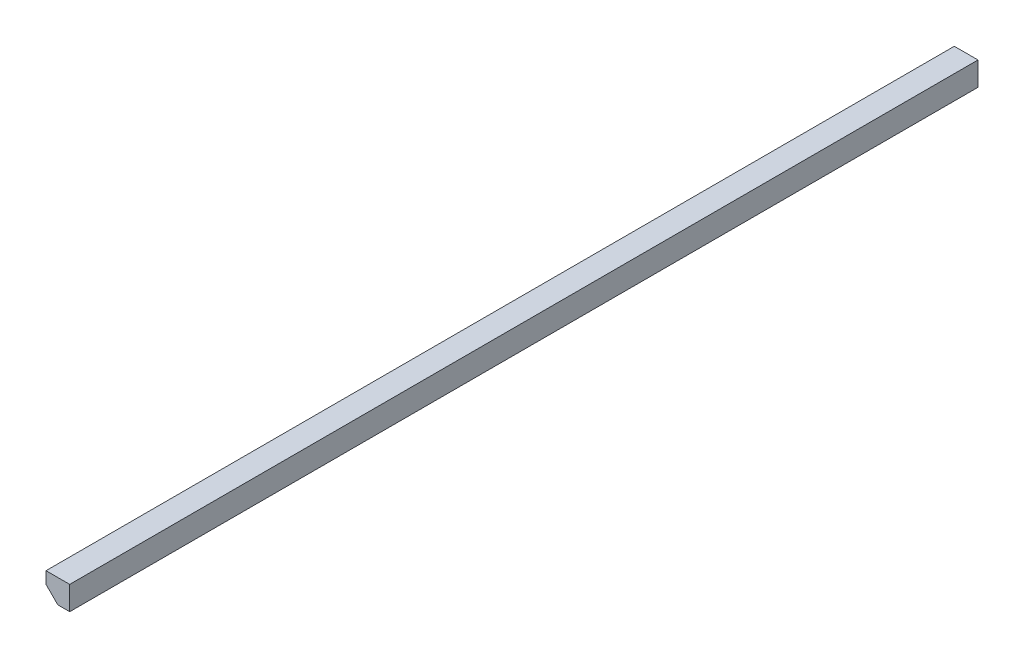
from build123d import *

# Parameters (mm, degrees)
EXTRUDE1_DEPTH = 365.125


with BuildPart() as part:
    # Sketch1 → Extrude1 (new body, symmetric)
    with BuildSketch(Plane.XY):
        Polygon((19.05, 0), (19.05, 19.05), (0, 19.05), (0, 9.525), (9.525, 0), align=None)
    extrude(amount=EXTRUDE1_DEPTH, both=True)


solid = part.part
